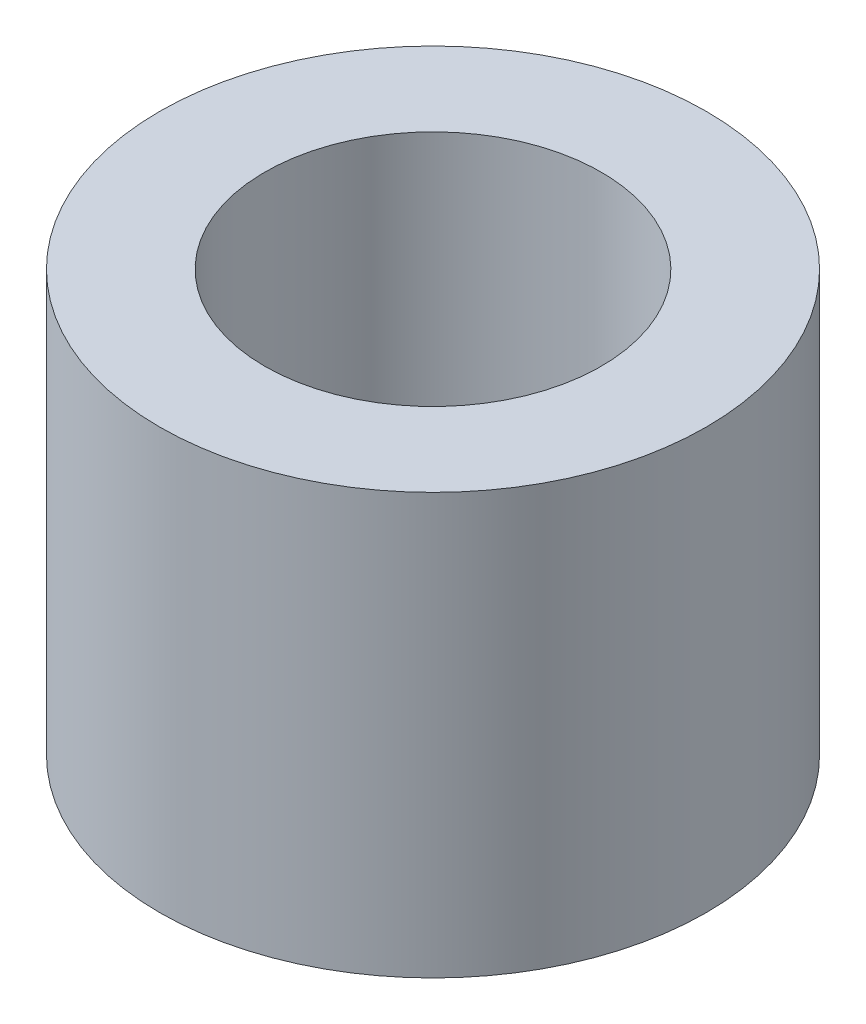
from build123d import *

# Parameters (mm, degrees)
SKETCH1_R           = 2.6
SKETCH1_R_2         = 1.6
BOSS_EXTRUDE1_DEPTH = 4


with BuildPart() as part:
    # Sketch1 → Boss-Extrude1 (new body)
    with BuildSketch(Plane(origin=(0, 0, 0), x_dir=(1, 0, 0), z_dir=(0, 1, 0))):
        Circle(SKETCH1_R)
        Circle(SKETCH1_R_2, mode=Mode.SUBTRACT)
    extrude(amount=BOSS_EXTRUDE1_DEPTH)


solid = part.part
